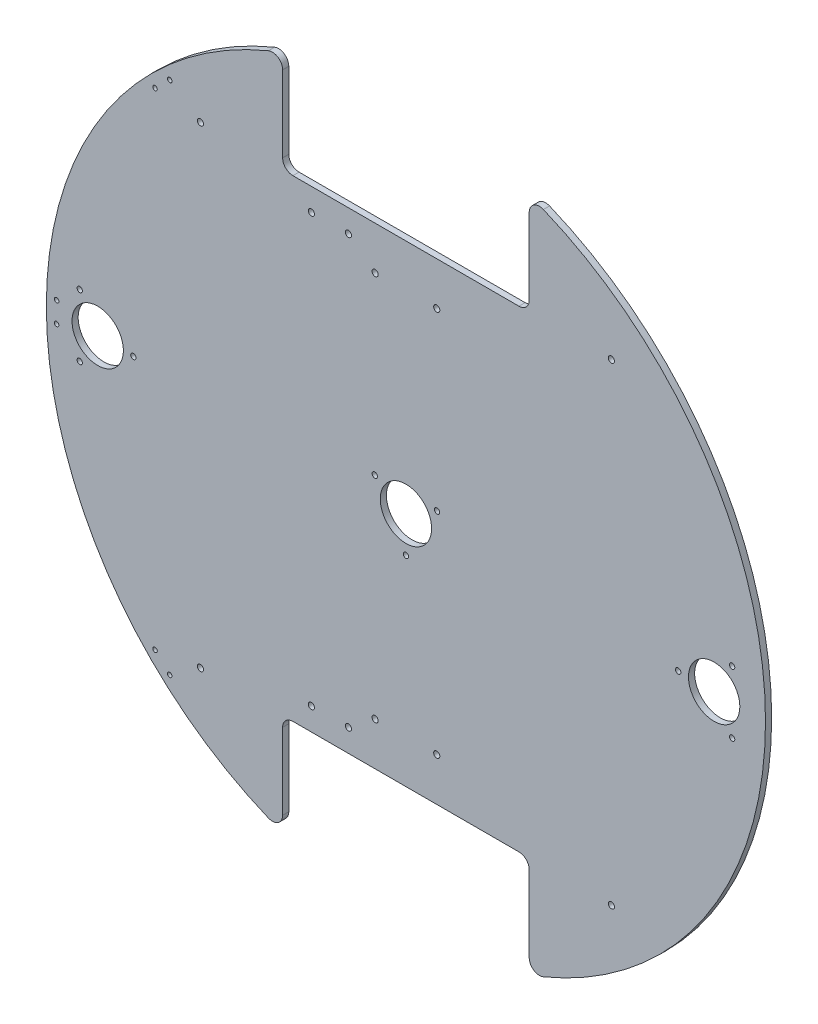
from build123d import *

# Parameters (mm, degrees)
SKETCH_1_R           = 175
EXTRUDE_1_DEPTH      = 3
CUT_EXTRUDE_1_DEPTH  = 3
FILLET_1_R           = 5
FILLET_2_R           = 5
FILLET_3_R           = 5
SKETCH_5_R           = 1.5
CUT_EXTRUDE_4_DEPTH  = 3
SKETCH_10_R          = 12.5
SKETCH_10_R_2        = 1.3
CUT_EXTRUDE_13_DEPTH = 10
SKETCH_14_R          = 1.1
CUT_EXTRUDE_14_DEPTH = 10
SKETCH_12_R          = 1.5
CUT_EXTRUDE_17_DEPTH = 10
SKETCH_13_R          = 1.5
CUT_EXTRUDE_18_DEPTH = 5


with BuildPart() as part:
    # ｽｹｯﾁ1 → ﾎﾞｽ - 押し出し1 (new body)
    with BuildSketch(Plane.XY):
        Circle(SKETCH_1_R)
    extrude(amount=EXTRUDE_1_DEPTH)

    # ｽｹｯﾁ2 → ｶｯﾄ - 押し出し1 (cut)
    with BuildSketch(Plane.XY.offset(3)):
        with BuildLine():
            Line((-60, 115), (0, 115))
            Line((0, 115), (0, 175))
            ThreePointArc((0, 175), (-30.465194158, 172.327803749), (-60, 164.392822228))
            Line((-60, 164.392822228), (-60, 115))
        make_face()
        with BuildLine():
            Line((0, 175), (0, 115))
            Line((0, 115), (60, 115))
            Line((60, 115), (60, 164.392822228))
            ThreePointArc((60, 164.392822228), (30.465194158, 172.327803749), (0, 175))
        make_face()
        with BuildLine():
            Line((0, -175), (0, -115))
            Line((0, -115), (-60, -115))
            Line((-60, -115), (-60, -164.392822228))
            ThreePointArc((-60, -164.392822228), (-30.465194158, -172.327803749), (0, -175))
        make_face()
        with BuildLine():
            Line((60, -115), (0, -115))
            Line((0, -115), (0, -175))
            ThreePointArc((0, -175), (30.465194158, -172.327803749), (60, -164.392822228))
            Line((60, -164.392822228), (60, -115))
        make_face()
    extrude(amount=-CUT_EXTRUDE_1_DEPTH, mode=Mode.SUBTRACT)

    # ﾌｨﾚｯﾄ1
    fillet_1_edges = [part.edges().sort_by_distance(p)[0] for p in [
        (-60, 164.392822228, 1.5),
    ]]
    fillet(fillet_1_edges, radius=FILLET_1_R)

    # ﾌｨﾚｯﾄ2
    fillet_2_edges = [part.edges().sort_by_distance(p)[0] for p in [
        (-60, 115, 1.5),
        (60, 164.392822228, 1.5),
        (60, 115, 1.5),
    ]]
    fillet(fillet_2_edges, radius=FILLET_2_R)

    # ﾌｨﾚｯﾄ3
    fillet_3_edges = [part.edges().sort_by_distance(p)[0] for p in [
        (-60, -115, 1.5),
        (60, -115, 1.5),
        (60, -164.392822228, 1.5),
        (-60, -164.392822228, 1.5),
    ]]
    fillet(fillet_3_edges, radius=FILLET_3_R)

    # ｽｹｯﾁ5 → ｶｯﾄ - 押し出し4 (cut)
    with BuildSketch(Plane.XY.offset(3)):
        with Locations((-100, -115)):
            Circle(SKETCH_5_R)
        with Locations((100, -115)):
            Circle(SKETCH_5_R)
        with Locations((100, 115)):
            Circle(SKETCH_5_R)
        with Locations((-100, 115)):
            Circle(SKETCH_5_R)
    extrude(amount=-CUT_EXTRUDE_4_DEPTH, mode=Mode.SUBTRACT)

    # ｽｹｯﾁ10 → ｶｯﾄ - 押し出し13 (cut)
    with BuildSketch(Plane.XY.offset(3)):
        with Locations((-150, 0)):
            Circle(SKETCH_10_R)
        with Locations((150, 0)):
            Circle(SKETCH_10_R)
        Circle(SKETCH_10_R)
        with Locations((132.5, 0)):
            Circle(SKETCH_10_R_2)
        with Locations((158.75, 15.155444566)):
            Circle(SKETCH_10_R_2)
        with Locations((158.75, -15.155444566)):
            Circle(SKETCH_10_R_2)
        with Locations((-15.155444566, 8.75)):
            Circle(SKETCH_10_R_2)
        with Locations((15.155444566, 8.75)):
            Circle(SKETCH_10_R_2)
        with Locations((0, -17.5)):
            Circle(SKETCH_10_R_2)
        with Locations((-158.75, 15.155444566)):
            Circle(SKETCH_10_R_2)
        with Locations((-158.75, -15.155444566)):
            Circle(SKETCH_10_R_2)
        with Locations((-132.632898389, 0)):
            Circle(SKETCH_10_R_2)
    extrude(amount=-CUT_EXTRUDE_13_DEPTH, mode=Mode.SUBTRACT)

    # ｽｹｯﾁ14 → ｶｯﾄ - 押し出し14 (cut)
    with BuildSketch(Plane.XY.offset(3)):
        with Locations((-170, 5)):
            Circle(SKETCH_14_R)
        with Locations((-170, -5)):
            Circle(SKETCH_14_R)
        with Locations((-114.933514447, 125.360628815)):
            Circle(SKETCH_14_R)
        with Locations((-122.102620524, 118.388977786)):
            Circle(SKETCH_14_R)
        with Locations((-122.102620524, -118.388977786)):
            Circle(SKETCH_14_R)
        with Locations((-114.933514447, -125.360628815)):
            Circle(SKETCH_14_R)
    extrude(amount=-CUT_EXTRUDE_14_DEPTH, mode=Mode.SUBTRACT)

    # ｽｹｯﾁ12 → ｶｯﾄ - 押し出し17 (cut)
    with BuildSketch(Plane.XY.offset(3)):
        with Locations((-15, 94)):
            Circle(SKETCH_12_R)
        with Locations((15, 94)):
            Circle(SKETCH_12_R)
        with Locations((-15, -94)):
            Circle(SKETCH_12_R)
        with Locations((15, -94)):
            Circle(SKETCH_12_R)
    extrude(amount=-CUT_EXTRUDE_17_DEPTH, mode=Mode.SUBTRACT)

    # ｽｹｯﾁ13 → ｶｯﾄ - 押し出し18 (cut)
    with BuildSketch(Plane.XY.offset(3)):
        with Locations((-28, -104)):
            Circle(SKETCH_13_R)
        with Locations((-46, -104)):
            Circle(SKETCH_13_R)
        with Locations((-46, 104)):
            Circle(SKETCH_13_R)
        with Locations((-28, 104)):
            Circle(SKETCH_13_R)
    extrude(amount=-CUT_EXTRUDE_18_DEPTH, mode=Mode.SUBTRACT)


solid = part.part
